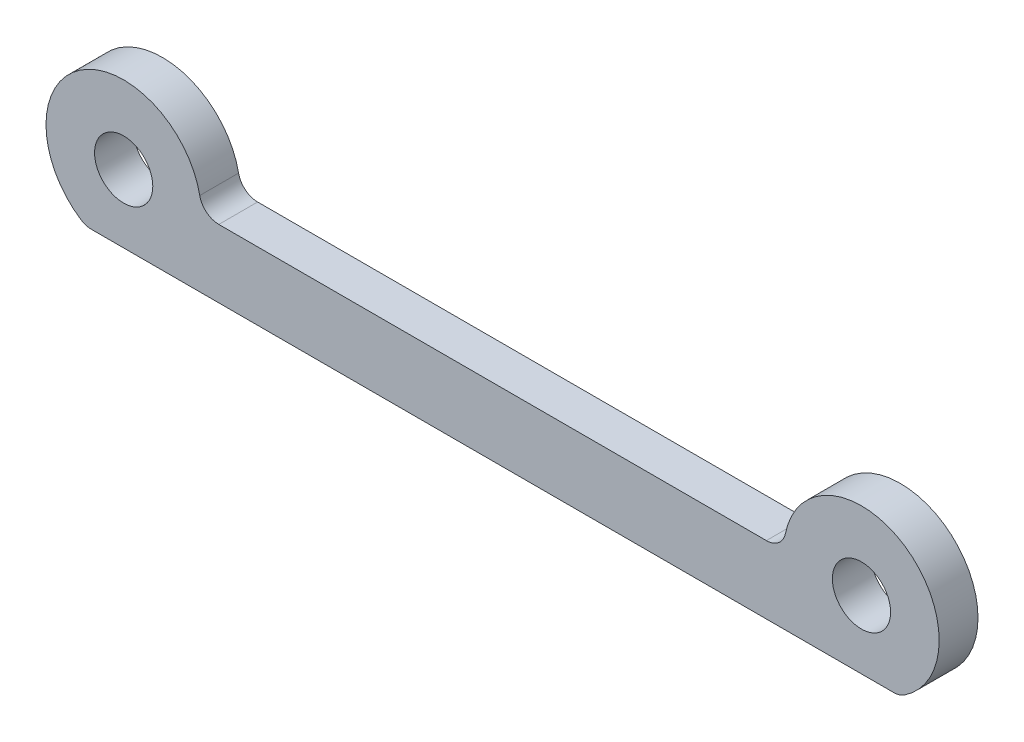
from build123d import *

# Parameters (mm, degrees)
CROQUIS1_R              = 1.5
SALIENTE_EXTRUIR1_DEPTH = 2
REDONDEO1_R             = 1


with BuildPart() as part:
    # Croquis1 → Saliente-Extruir1 (new body)
    with BuildSketch(Plane.XY):
        with BuildLine():
            Line((15, 3.5), (-15, 3.5))
            ThreePointArc((-15, 3.5), (-21.031506006, 6.945719569), (-20.936491673, 0))
            Line((-20.936491673, 0), (20.936491673, 0))
            ThreePointArc((20.936491673, 0), (21.031506006, 6.945719569), (15, 3.5))
        make_face()
        with Locations((-19, 3.5)):
            Circle(CROQUIS1_R, mode=Mode.SUBTRACT)
        with Locations((19, 3.5)):
            Circle(CROQUIS1_R, mode=Mode.SUBTRACT)
    extrude(amount=SALIENTE_EXTRUIR1_DEPTH)

    # Redondeo1
    redondeo1_edges = [part.edges().sort_by_distance(p)[0] for p in [
        (20.936491673, 0, 1),
        (-20.936491673, 0, 1),
        (-15, 3.5, 1),
        (15, 3.5, 1),
    ]]
    fillet(redondeo1_edges, radius=REDONDEO1_R)


solid = part.part
